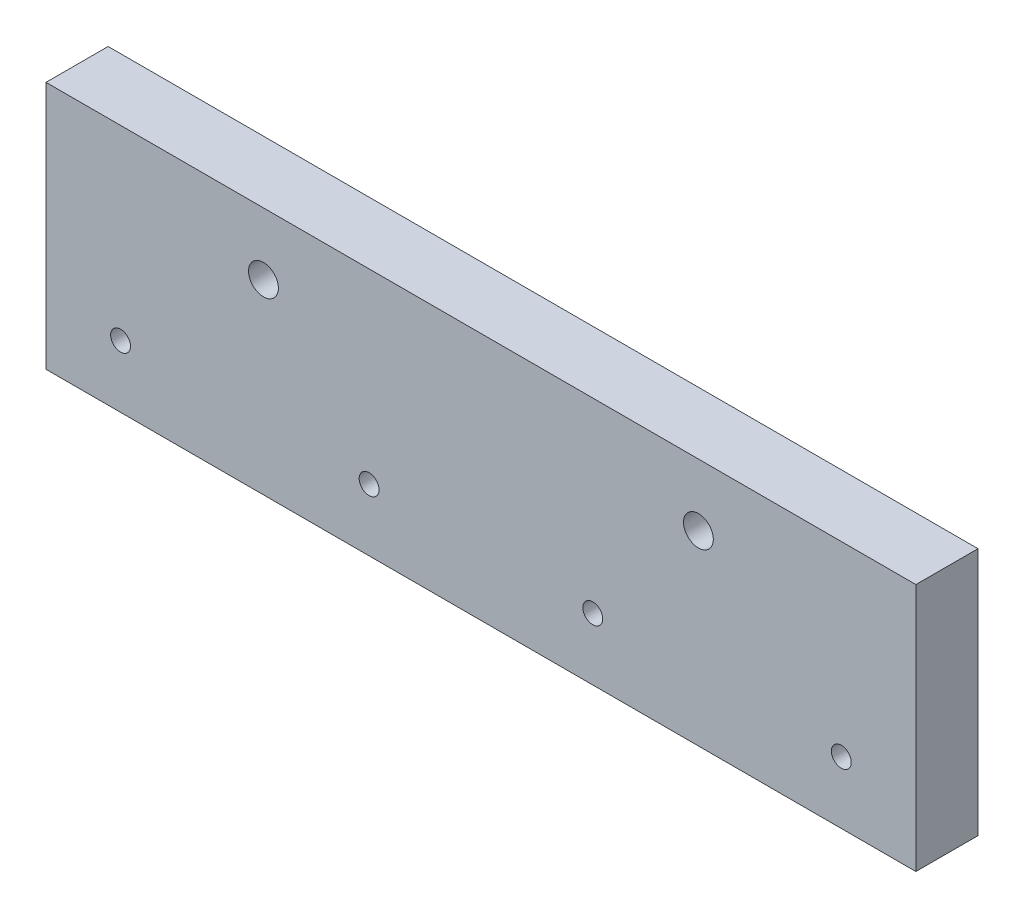
from build123d import *

# Parameters (mm, degrees)
SKETCH1_W           = 88.9
SKETCH1_H           = 25.4
BOSS_EXTRUDE1_DEPTH = 6.35
SKETCH2_R           = 1.016
CUT_EXTRUDE1_DEPTH  = 7.35
SKETCH3_R           = 1.524
CUT_EXTRUDE2_DEPTH  = 7.35


with BuildPart() as part:
    # Sketch1 → Boss-Extrude1 (new body)
    with BuildSketch(Plane.XY):
        with Locations((44.45, 12.7)):
            Rectangle(SKETCH1_W, SKETCH1_H)
    extrude(amount=BOSS_EXTRUDE1_DEPTH)

    # Sketch2 → Cut-Extrude1 (cut, through all)
    with BuildSketch(Plane.XY.offset(6.35)):
        with Locations((7.62, 6.35)):
            Circle(SKETCH2_R)
        with Locations((33.02, 6.35)):
            Circle(SKETCH2_R)
        with Locations((55.88, 6.35)):
            Circle(SKETCH2_R)
        with Locations((81.28, 6.35)):
            Circle(SKETCH2_R)
    extrude(amount=-CUT_EXTRUDE1_DEPTH, mode=Mode.SUBTRACT)

    # Sketch3 → Cut-Extrude2 (cut, through all)
    with BuildSketch(Plane.XY.offset(6.35)):
        with Locations((22.225, 19.05)):
            Circle(SKETCH3_R)
        with Locations((66.675, 19.05)):
            Circle(SKETCH3_R)
    extrude(amount=-CUT_EXTRUDE2_DEPTH, mode=Mode.SUBTRACT)


solid = part.part
